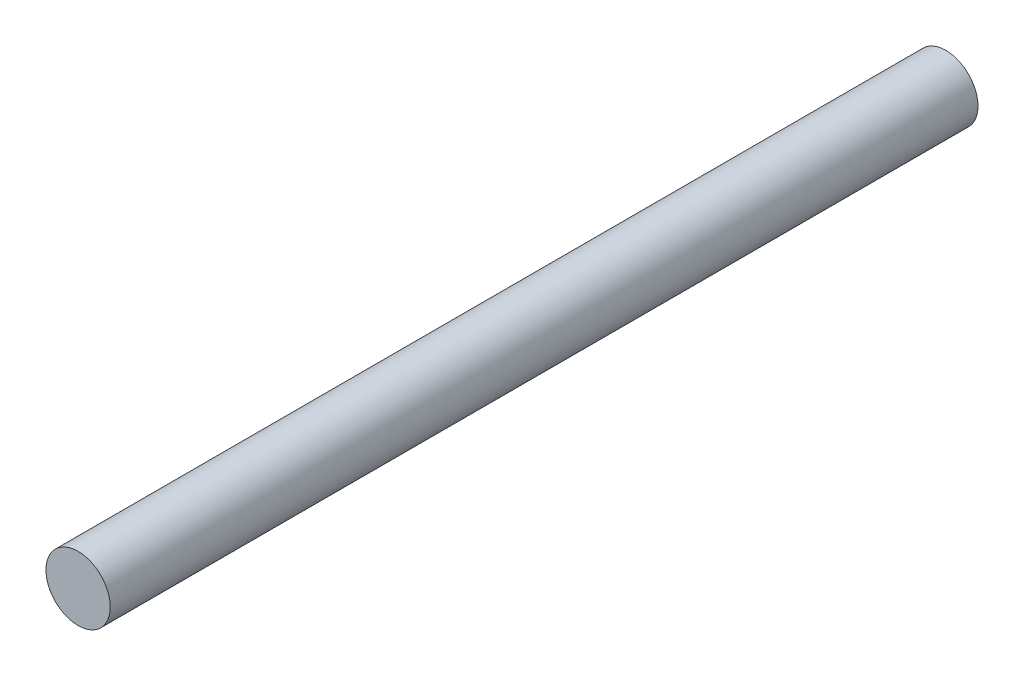
from build123d import *

# Parameters (mm, degrees)
SKETCH1_R           = 4
BOSS_EXTRUDE1_DEPTH = 107.95


with BuildPart() as part:
    # Sketch1 → Boss-Extrude1 (new body)
    with BuildSketch(Plane.XY):
        Circle(SKETCH1_R)
    extrude(amount=BOSS_EXTRUDE1_DEPTH)


solid = part.part
